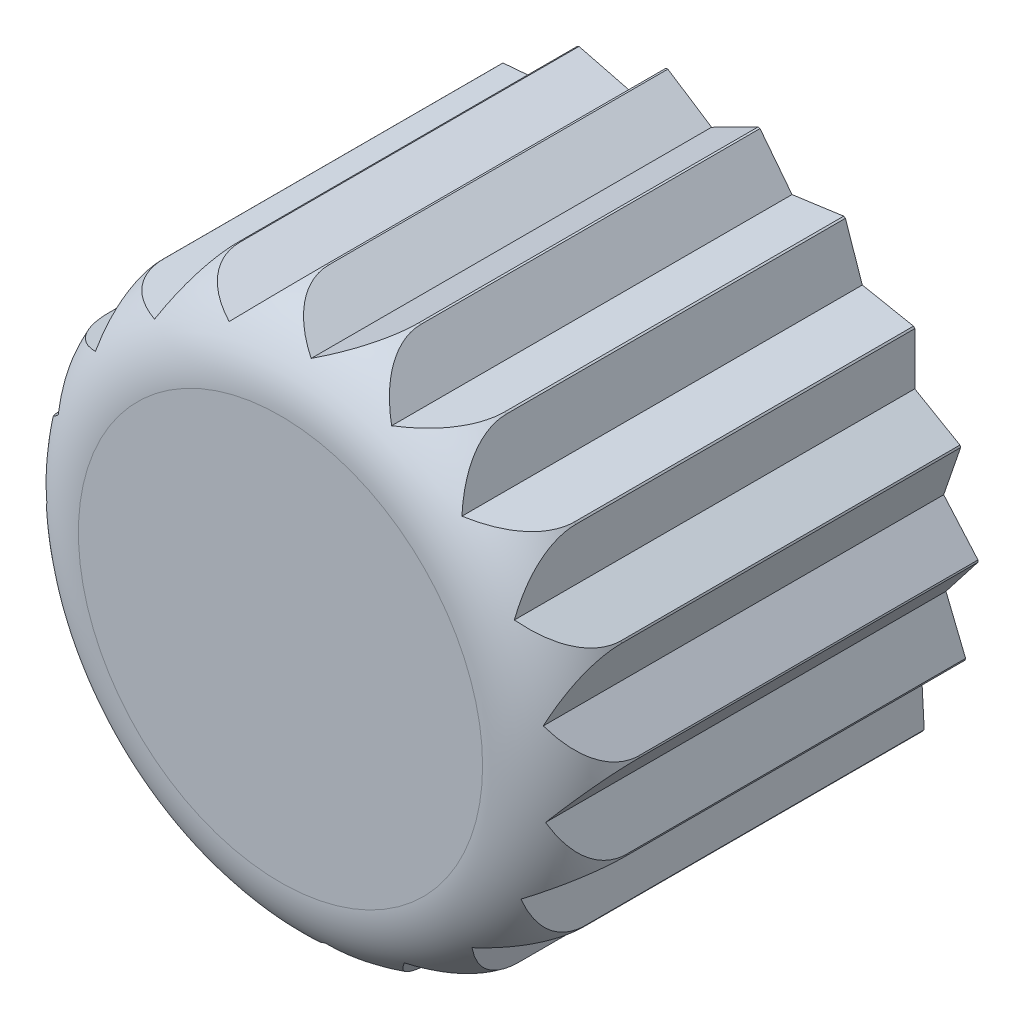
from build123d import *

# Parameters (mm, degrees)
SKETCH2_R           = 5.375
BOSS_EXTRUDE1_DEPTH = 2
SKETCH3_R           = 5.375
SKETCH3_R_2         = 3.375
BOSS_EXTRUDE2_DEPTH = 6
FILLET1_R           = 1.5
CUT_EXTRUDE1_DEPTH  = 8


with BuildPart() as part:
    # Sketch2 → Boss-Extrude1 (new body)
    with BuildSketch(Plane.XY):
        Circle(SKETCH2_R)
    extrude(amount=BOSS_EXTRUDE1_DEPTH)

    # Sketch3 → Boss-Extrude2 (add)
    with BuildSketch(Plane(origin=(0, 0, 0), x_dir=(-1, 0, 0), z_dir=(0, 0, -1))):
        Circle(SKETCH3_R)
        Circle(SKETCH3_R_2, mode=Mode.SUBTRACT)
    extrude(amount=BOSS_EXTRUDE2_DEPTH)

    # Fillet1
    fillet1_edges = [part.edges().sort_by_distance(p)[0] for p in [
        (-5.375, 0, 2),
    ]]
    fillet(fillet1_edges, radius=FILLET1_R)

    # Sketch4 → Cut-Extrude1 (cut)
    with BuildSketch(Plane.XY.offset(2)):
        with BuildLine():
            Line((-2.737798822, 3.948456511), (-2.311022387, 4.852813671))
            ThreePointArc((-2.311022387, 4.852813671), (-3.062718309, 4.417055757), (-3.734383315, 3.865877165))
            Line((-3.734383315, 3.865877165), (-2.737798822, 3.948456511))
        make_face()
        with BuildLine():
            Line((-1.307395597, 4.62348007), (-0.610098796, 5.340262583))
            ThreePointArc((-0.610098796, 5.340262583), (-1.462556124, 5.172190502), (-2.276795863, 4.868965557))
            Line((-2.276795863, 4.868965557), (-1.307395597, 4.62348007))
        make_face()
        with BuildLine():
            Line((-3.871519063, 2.845556422), (-3.761510842, 3.839487099))
            ThreePointArc((-3.761510842, 3.839487099), (-4.330987443, 3.183264483), (-4.78729239, 2.443860997))
            Line((-4.78729239, 2.443860997), (-3.871519063, 2.845556422))
        make_face()
        with BuildLine():
            Line((-4.585700141, 1.434296141), (-4.804381233, 2.410092523))
            ThreePointArc((-4.804381233, 2.410092523), (-5.129926885, 1.604517109), (-5.321424052, 0.757014569))
            Line((-5.321424052, 0.757014569), (-4.585700141, 1.434296141))
        make_face()
        with BuildLine():
            Line((-4.802949455, -0.132392382), (-5.326622369, 0.719527027))
            ThreePointArc((-5.326622369, 0.719527027), (-5.37295915, -0.14810459), (-5.278896848, -1.011866133))
            Line((-5.278896848, -1.011866133), (-4.802949455, -0.132392382))
        make_face()
        with BuildLine():
            ThreePointArc((-5.27164132, -1.049010388), (-5.033747921, -1.884676859), (-4.664319259, -2.67109544))
            Line((-4.664319259, -2.67109544), (-4.499724669, -1.684734136))
            Line((-4.499724669, -1.684734136), (-5.27164132, -1.049010388))
        make_face()
        with BuildLine():
            ThreePointArc((-4.645396136, -2.70387125), (-4.149051999, -3.417015147), (-3.544290305, -4.040870109))
            Line((-3.544290305, -4.040870109), (-3.708884895, -3.054508805))
            Line((-3.708884895, -3.054508805), (-4.645396136, -2.70387125))
        make_face()
        with BuildLine():
            ThreePointArc((-3.515750201, -4.065725707), (-2.814741913, -4.579066823), (-2.0401825, -4.972753801))
            Line((-2.0401825, -4.972753801), (-2.516129893, -4.09328005))
            Line((-2.516129893, -4.09328005), (-3.515750201, -4.065725707))
        make_face()
        with BuildLine():
            ThreePointArc((-2.005118178, -4.986995698), (-1.175410865, -5.244905557), (-0.314989265, -5.365762459))
            Line((-0.314989265, -5.365762459), (-1.050713176, -4.688480887))
            Line((-1.050713176, -4.688480887), (-2.005118178, -4.986995698))
        make_face()
        with BuildLine():
            ThreePointArc((-0.277200488, -5.367847324), (0.591294188, -5.342377391), (1.444337944, -5.177307496))
            Line((1.444337944, -5.177307496), (0.528564617, -4.775612071))
            Line((0.528564617, -4.775612071), (-0.277200488, -5.367847324))
        make_face()
        with BuildLine():
            ThreePointArc((1.480756175, -5.167009401), (2.293923341, -4.860919739), (3.047148726, -4.427810931))
            Line((3.047148726, -4.427810931), (2.050564233, -4.345231586))
            Line((2.050564233, -4.345231586), (1.480756175, -5.167009401))
        make_face()
        with BuildLine():
            ThreePointArc((3.078249931, -4.406245835), (3.747970306, -3.852706008), (4.319753662, -3.198492348))
            Line((4.319753662, -3.198492348), (3.350353396, -3.443977835))
            Line((3.350353396, -3.443977835), (3.078249931, -4.406245835))
        make_face()
        with BuildLine():
            ThreePointArc((4.342167543, -3.167997163), (4.795866533, -2.426991801), (5.124246261, -1.622567489))
            Line((5.124246261, -1.622567489), (4.287079783, -2.169515647))
            Line((4.287079783, -2.169515647), (4.342167543, -3.167997163))
        make_face()
        with BuildLine():
            ThreePointArc((5.375, 0), (5.374611803, 0.064598533), (5.373447267, 0.129187734))
            Line((5.373447267, 0.129187734), (4.759234554, -0.659952775))
            Line((4.759234554, -0.659952775), (5.135543926, -1.586446842))
            ThreePointArc((5.135543926, -1.586446842), (5.314798849, -0.802208326), (5.375, 0))
        make_face()
        with BuildLine():
            ThreePointArc((5.372404438, 0.16701961), (5.275301776, 1.030444647), (5.040351884, 1.866943462))
            Line((5.040351884, 1.866943462), (4.715652414, 0.92112622))
            Line((4.715652414, 0.92112622), (5.372404438, 0.16701961))
        make_face()
        with BuildLine():
            Line((4.161056165, 2.402386897), (5.027081568, 1.902386897))
            ThreePointArc((5.027081568, 1.902386897), (4.654886545, 2.6875), (4.161056165, 3.402386897))
            Line((4.161056165, 3.402386897), (4.161056165, 2.402386897))
        make_face()
        with BuildLine():
            Line((3.155544914, 3.623311676), (4.136996407, 3.431601044))
            ThreePointArc((4.136996407, 3.431601044), (3.530042129, 4.053323028), (2.830845445, 4.569128918))
            Line((2.830845445, 4.569128918), (3.155544914, 3.623311676))
        make_face()
        with BuildLine():
            Line((1.808081409, 4.451594414), (2.798603493, 4.588947972))
            ThreePointArc((2.798603493, 4.588947972), (2.022662874, 4.979905611), (1.193868696, 5.240734923))
            Line((1.193868696, 5.240734923), (1.808081409, 4.451594414))
        make_face()
        with BuildLine():
            Line((0.264684227, 4.797477823), (1.156938466, 5.249011182))
            ThreePointArc((1.156938466, 5.249011182), (0.296096712, 5.366838151), (-0.572482251, 5.344425982))
            Line((-0.572482251, 5.344425982), (0.264684227, 4.797477823))
        make_face()
    extrude(amount=-CUT_EXTRUDE1_DEPTH, mode=Mode.SUBTRACT)


solid = part.part
